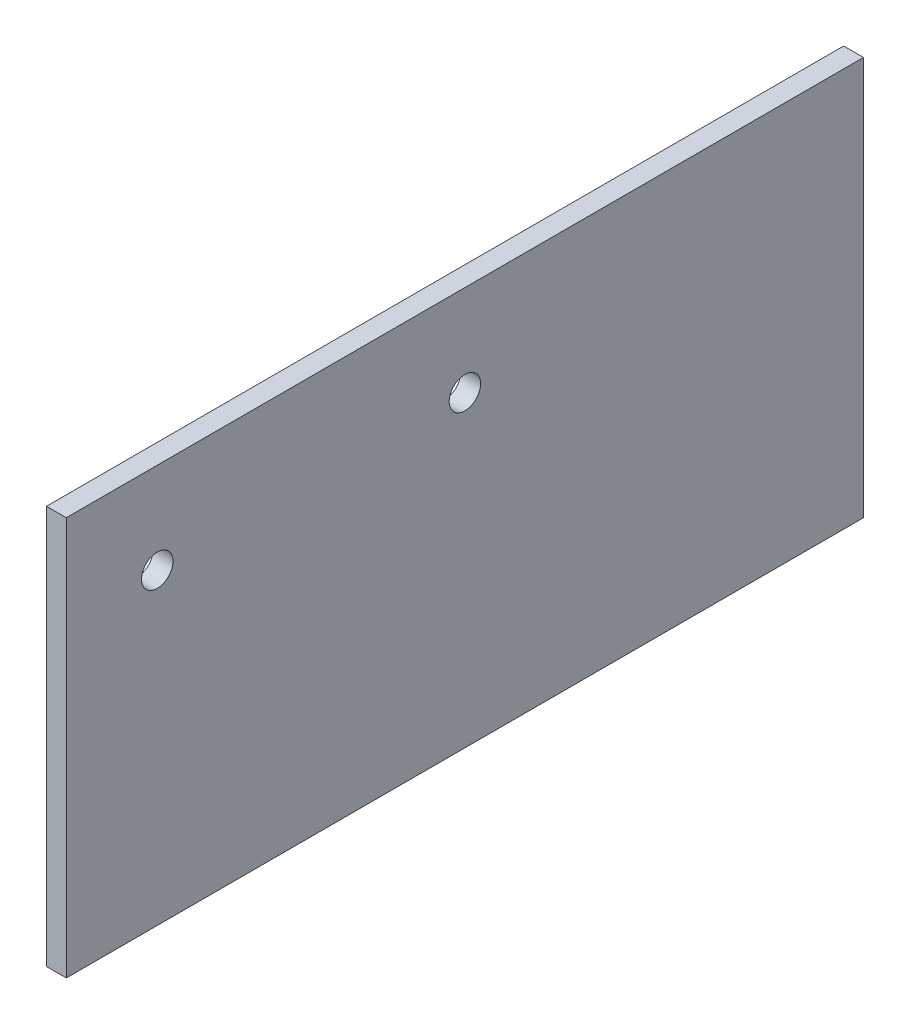
from build123d import *

# Parameters (mm, degrees)
SKETCH1_W               = 181
SKETCH1_H               = 90.5
BOSS_EXTRUDE1_DEPTH     = 2.25
SKETCH2_R               = 3.5687
CUT_EXTRUDE1_DEPTH      = 1
CUT_EXTRUDE1_DEPTH_BACK = 91.5


with BuildPart() as part:
    # Sketch1 → Boss-Extrude1 (new body, symmetric)
    with BuildSketch(Plane(origin=(0, 0, 0), x_dir=(0, 0, -1), z_dir=(1, 0, 0))):
        with Locations((0, 45.25)):
            Rectangle(SKETCH1_W, SKETCH1_H)
    extrude(amount=BOSS_EXTRUDE1_DEPTH, both=True)

    # Sketch2 → Cut-Extrude1 (cut, two sides)
    with BuildSketch(Plane(origin=(88.25, 0, 0), x_dir=(0, 0, -1), z_dir=(1, 0, 0))) as cut_extrude1_sk:
        with Locations((-69.85, 69.85)):
            Circle(SKETCH2_R)
        with Locations((0, 69.85)):
            Circle(SKETCH2_R)
    extrude(amount=CUT_EXTRUDE1_DEPTH, mode=Mode.SUBTRACT)
    extrude(cut_extrude1_sk.sketch, amount=-CUT_EXTRUDE1_DEPTH_BACK, mode=Mode.SUBTRACT)


solid = part.part
